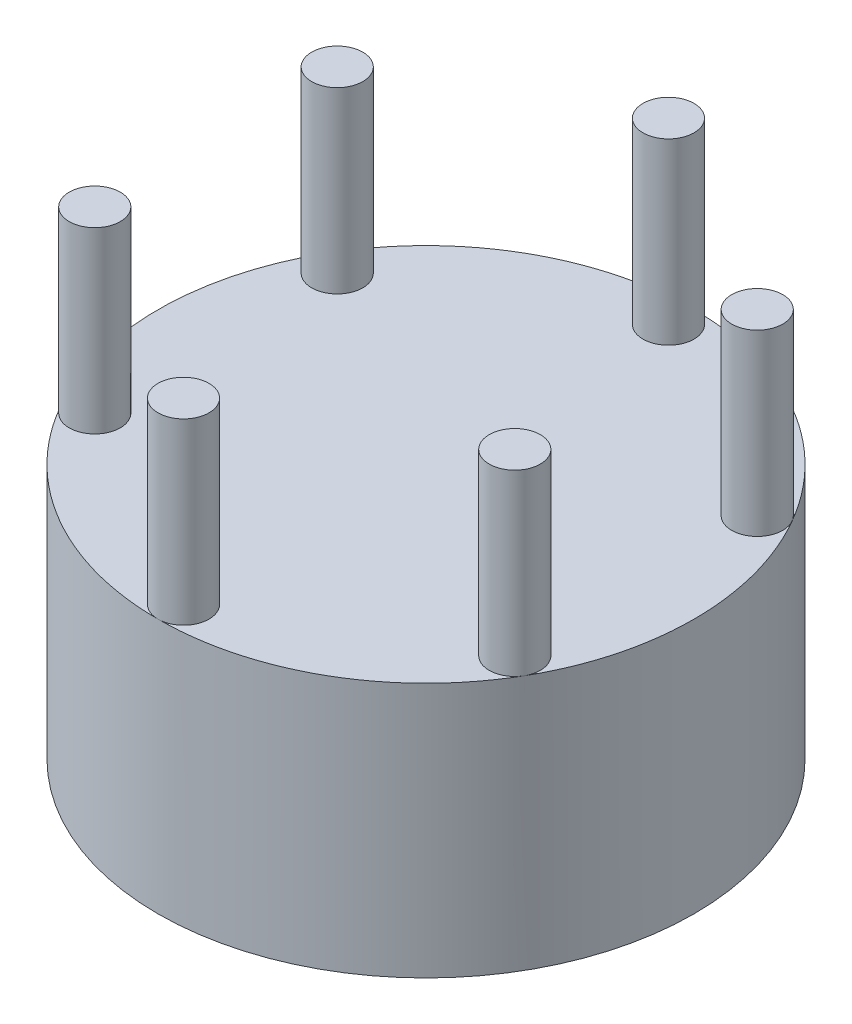
from build123d import *

# Parameters (mm, degrees)
SKETCH1_R           = 21
BOSS_EXTRUDE1_DEPTH = 20
SKETCH2_R           = 2
BOSS_EXTRUDE3_DEPTH = 14
CIRPATTERN1_COUNT   = 6


with BuildPart() as part:
    # Sketch1 → Boss-Extrude1 (new body)
    with BuildSketch(Plane(origin=(0, 0, 0), x_dir=(1, 0, 0), z_dir=(0, 1, 0))):
        Circle(SKETCH1_R)
    extrude(amount=BOSS_EXTRUDE1_DEPTH)

    # Sketch2 → Boss-Extrude3 (add)
    with BuildSketch(Plane(origin=(0, 20, 0), x_dir=(1, 0, 0), z_dir=(0, 1, 0))):
        with Locations((0, -19)):
            Circle(SKETCH2_R)
    boss_extrude3 = extrude(amount=BOSS_EXTRUDE3_DEPTH)

    # CirPattern1: Boss-Extrude3 ×6 about axis
    cirpattern1_axis = Axis((0, 0, 0), (0, 1, 0))
    for i in range(1, CIRPATTERN1_COUNT):
        add(boss_extrude3.rotate(cirpattern1_axis, i * 360 / CIRPATTERN1_COUNT))


solid = part.part
